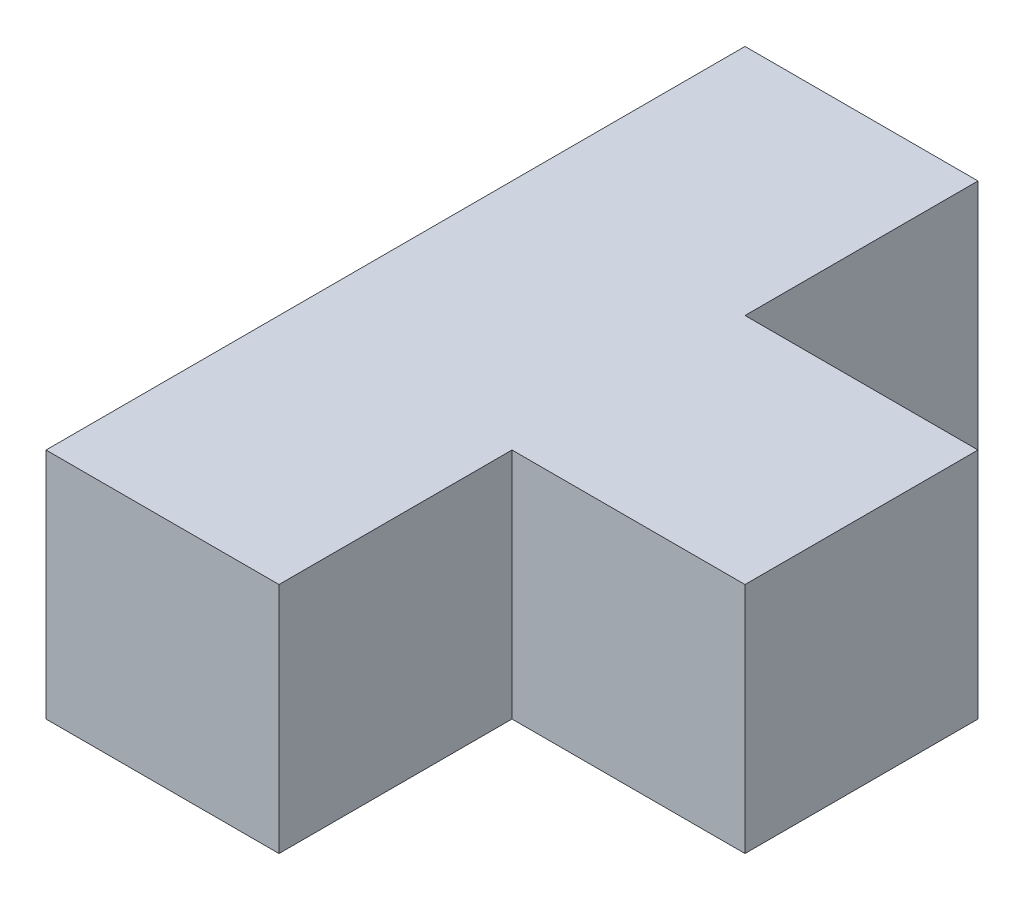
from build123d import *

# Parameters (mm, degrees)
BOSS_EXTRUDE1_DEPTH = 5000


with BuildPart() as part:
    # Sketch1 → Boss-Extrude1 (new body)
    with BuildSketch(Plane(origin=(0, 0, 0), x_dir=(1, 0, 0), z_dir=(0, 1, 0))):
        Polygon((-5000, 7500), (-5000, -7500), (0, -7500), (0, -2500), (5000, -2500), (5000, 2500), (0, 2500), (0, 7500), align=None)
    extrude(amount=BOSS_EXTRUDE1_DEPTH)


solid = part.part
